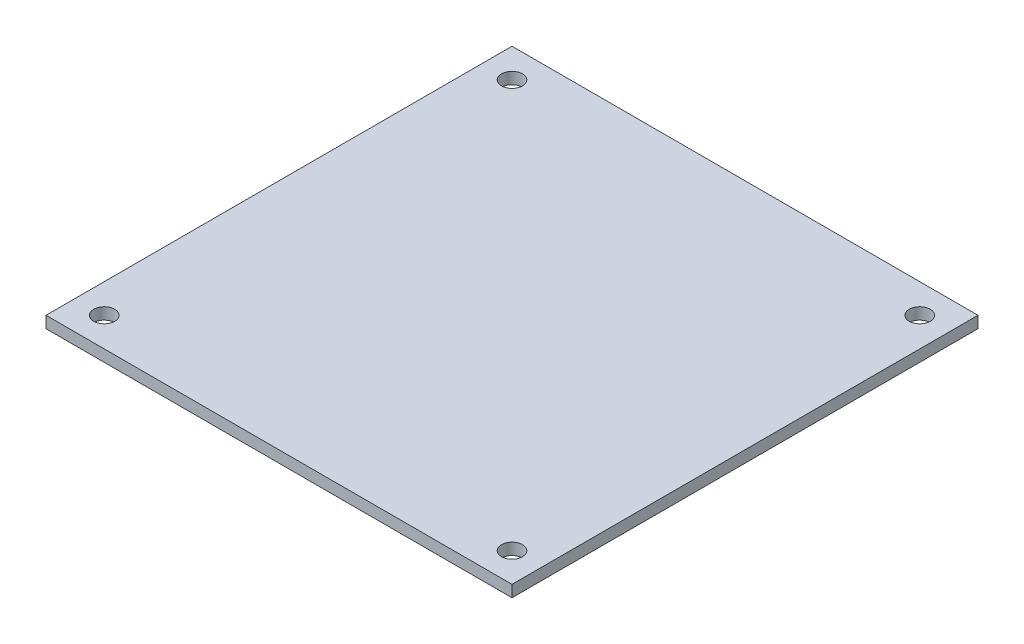
from build123d import *

# Parameters (mm, degrees)
SKETCH1_W              = 80
SKETCH1_H              = 80
PCB_DEPTH              = 2
SKETCH2_R              = 1.8
ATTACHMENT_HOLES_DEPTH = 3
LPATTERN1_COUNT        = 2
LPATTERN1_PITCH        = 70
LPATTERN1_COUNT_DIR2   = 2
LPATTERN1_PITCH_DIR2   = 70


with BuildPart() as part:
    # Sketch1 → PCB (new body)
    with BuildSketch(Plane(origin=(0, 0, 0), x_dir=(1, 0, 0), z_dir=(0, 1, 0))):
        with Locations((40, 40)):
            Rectangle(SKETCH1_W, SKETCH1_H)
    extrude(amount=PCB_DEPTH)

    # Sketch2 → Attachment Holes (cut, through all)
    with BuildSketch(Plane(origin=(0, 2, 0), x_dir=(1, 0, 0), z_dir=(0, 1, 0))):
        with Locations((5, 75)):
            Circle(SKETCH2_R)
    attachment_holes = extrude(amount=-ATTACHMENT_HOLES_DEPTH, mode=Mode.SUBTRACT)

    # LPattern1: Attachment Holes 2 × 2
    with Locations(*[(i * LPATTERN1_PITCH, 0, j * LPATTERN1_PITCH_DIR2) for i in range(LPATTERN1_COUNT) for j in range(LPATTERN1_COUNT_DIR2) if (i, j) != (0, 0)]):
        add(attachment_holes, mode=Mode.SUBTRACT)


solid = part.part
